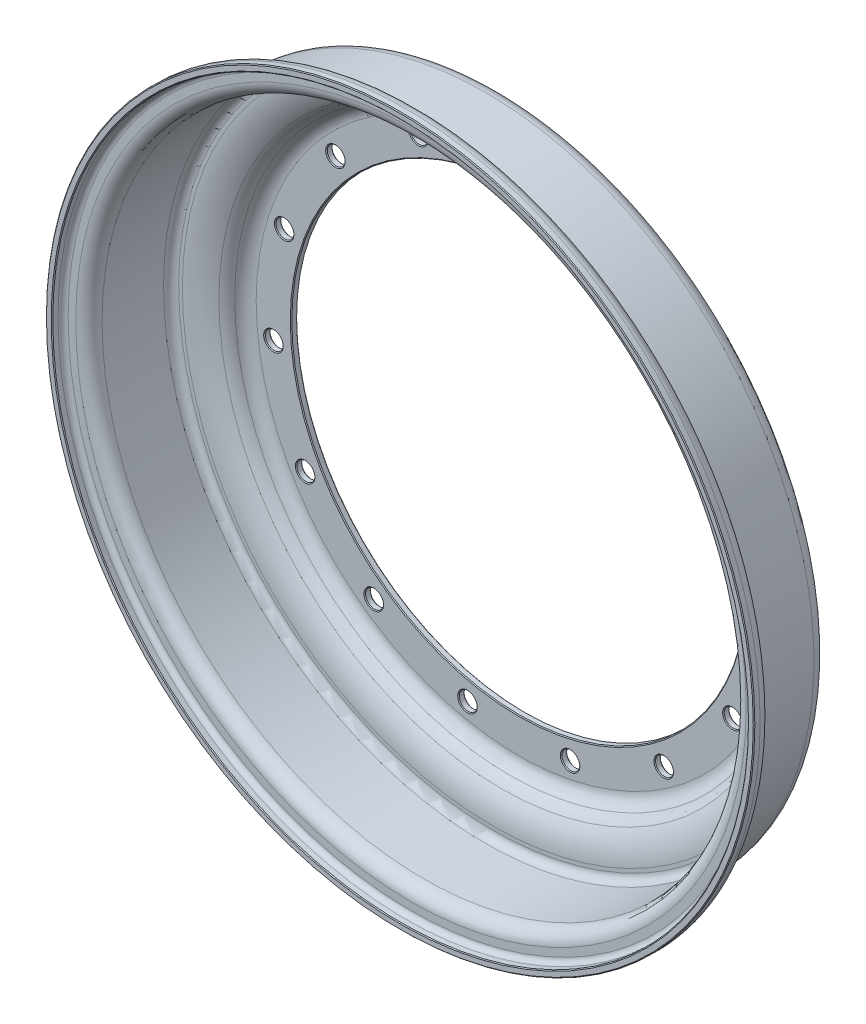
from build123d import *

# Parameters (mm, degrees)
SKETCH2_R                   = 4.49834
MOUNTING_HOLE_DEPTH         = 4.175
MOUNTING_HOLE_PATTERN_COUNT = 15
EDGE_CHAMFER_SIZE           = 0.39624


with BuildPart() as part:
    # Sketch1 → Inner Rim (revolve)
    with BuildSketch(Plane(origin=(0, 0, 0), x_dir=(0, 0, -1), z_dir=(1, 0, 0))):
        with BuildLine():
            Line((0, 114.3), (0, 131.81076))
            ThreePointArc((0, 131.81076), (-1.708204623, 137.450036516), (-6.25856, 141.19352))
            ThreePointArc((-6.25856, 141.19352), (-7.886461195, 142.179734532), (-9.14908, 143.60398))
            ThreePointArc((-9.14908, 143.60398), (-11.886505839, 149.554103055), (-12.824644135, 156.036183055))
            Line((-12.824644135, 156.036183055), (-12.824644135, 157.862443055))
            ThreePointArc((-12.824644135, 157.862443055), (-14.870457346, 162.801473055), (-19.809487346, 164.847286266))
            Line((-19.809487346, 164.847286266), (-50.670487346, 164.847286266))
            ThreePointArc((-50.670487346, 164.847286266), (-53.094917346, 165.851518053), (-54.099149133, 168.275948053))
            Line((-54.099149133, 168.275948053), (-54.099149133, 172.085948053))
            ThreePointArc((-54.099149133, 172.085948053), (-55.773044128, 176.127088053), (-59.814184128, 177.800983048))
            Line((-59.814184128, 177.800983048), (-62.862184128, 177.800983048))
            Line((-62.862184128, 177.800983048), (-62.862184128, 174.625983048))
            Line((-62.862184128, 174.625983048), (-59.814184128, 174.625983048))
            ThreePointArc((-59.814184128, 174.625983048), (-58.018108159, 173.882024022), (-57.274149133, 172.085948053))
            Line((-57.274149133, 172.085948053), (-57.274149133, 168.275948053))
            ThreePointArc((-57.274149133, 168.275948053), (-55.339981376, 163.606454022), (-50.670487346, 161.672286266))
            Line((-50.670487346, 161.672286266), (-19.809487346, 161.672286266))
            ThreePointArc((-19.809487346, 161.672286266), (-17.115521376, 160.556409025), (-15.999644135, 157.862443055))
            Line((-15.999644135, 157.862443055), (-15.999644135, 156.036183055))
            ThreePointArc((-15.999644135, 156.036183055), (-14.931226414, 148.653935506), (-11.813653785, 141.877517854))
            ThreePointArc((-11.813653785, 141.877517854), (-9.919889574, 139.741334641), (-7.478249224, 138.26214094))
            ThreePointArc((-7.478249224, 138.26214094), (-4.349524206, 135.68820342), (-3.175, 131.81076))
            Line((-3.175, 131.81076), (-3.175, 114.3))
            Line((-3.175, 114.3), (0, 114.3))
        make_face()
    revolve(axis=Axis((0, 0, -1.873109206), (0, 0, 1)))

    # Sketch2 → Mounting Hole (cut, through all)
    with BuildSketch(Plane.XY.offset(3.175)):
        with Locations((0, 123.825)):
            Circle(SKETCH2_R)
    mounting_hole = extrude(amount=-MOUNTING_HOLE_DEPTH, mode=Mode.SUBTRACT)

    # Mounting Hole Pattern: Mounting Hole ×15 about axis
    mounting_hole_pattern_axis = Axis((0, 0, 0), (0, 0, 1))
    for i in range(1, MOUNTING_HOLE_PATTERN_COUNT):
        add(mounting_hole.rotate(mounting_hole_pattern_axis, i * 360 / MOUNTING_HOLE_PATTERN_COUNT), mode=Mode.SUBTRACT)

    # Edge Chamfer
    edge_chamfer_edges = [part.edges().sort_by_distance(p)[0] for p in [
        (89.009931043, 86.198015427, 0),
        (89.009931043, 86.198015427, 3.175),
        (46.254726755, 114.949406004, 0),
        (46.254726755, 114.949406004, 3.175),
        (0, -114.3, 3.175),
        (0, -174.625983048, 62.862184128),
        (0, -177.800983048, 62.862184128),
        (0, -114.3, 0),
        (-4.49834, 123.825, 0),
        (-4.49834, 123.825, 3.175),
        (-54.473602903, 111.290126582, 0),
        (-54.473602903, 111.290126582, 3.175),
        (-95.029884987, 79.512179238, 0),
        (-95.029884987, 79.512179238, 3.175),
        (-119.154636637, 33.985853759, 0),
        (-119.154636637, 33.985853759, 3.175),
        (-122.676469127, -17.416934587, 0),
        (-122.676469127, -17.416934587, 3.175),
        (-104.986425624, -65.808176715, 0),
        (-104.986425624, -65.808176715, 3.175),
        (-69.143275359, -102.82058724, 0),
        (-69.143275359, -102.82058724, 3.175),
        (-21.344624637, -122.054384136, 0),
        (-21.344624637, -122.054384136, 3.175),
        (30.144705594, -120.183869186, 0),
        (30.144705594, -120.183869186, 3.175),
        (76.421742372, -97.532471417, 0),
        (76.421742372, -97.532471417, 3.175),
        (109.484765624, -58.016823285, 0),
        (109.484765624, -58.016823285, 3.175),
        (123.616878261, -8.469539341, 0),
        (123.616878261, -8.469539341, 3.175),
        (116.374509624, 42.542204898, 0),
        (116.374509624, 42.542204898, 3.175),
    ]]
    chamfer(edge_chamfer_edges, length=EDGE_CHAMFER_SIZE)


solid = part.part
